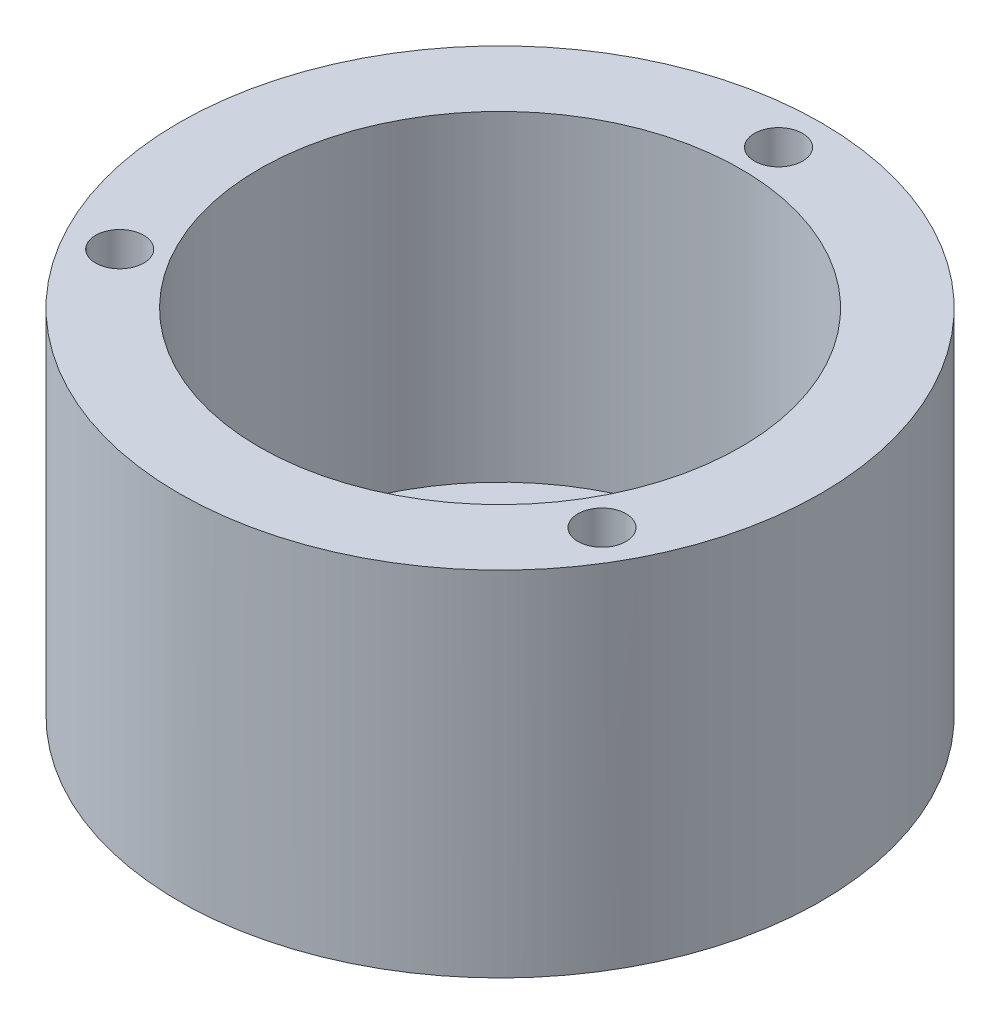
from build123d import *

# Parameters (mm, degrees)
SKETCH1_R           = 20
SKETCH1_R_2         = 15
BOSS_EXTRUDE1_DEPTH = 20
SKETCH2_R           = 20
SKETCH2_R_2         = 3
SKETCH2_R_3         = 2
BOSS_EXTRUDE2_DEPTH = 2
SKETCH3_R           = 1.5
CUT_EXTRUDE1_DEPTH  = 4


with BuildPart() as part:
    # Sketch1 → Boss-Extrude1 (new body)
    with BuildSketch(Plane(origin=(0, 0, 0), x_dir=(1, 0, 0), z_dir=(0, 1, 0))):
        Circle(SKETCH1_R)
        Circle(SKETCH1_R_2, mode=Mode.SUBTRACT)
    extrude(amount=BOSS_EXTRUDE1_DEPTH)

    # Sketch2 → Boss-Extrude2 (add)
    with BuildSketch(Plane.XZ):
        Circle(SKETCH2_R)
        Circle(SKETCH2_R_2, mode=Mode.SUBTRACT)
        with Locations((6, 7.463372557)):
            Circle(SKETCH2_R_3, mode=Mode.SUBTRACT)
        with Locations((7.463372557, -6)):
            Circle(SKETCH2_R_3, mode=Mode.SUBTRACT)
        with Locations((-6, -7.463372557)):
            Circle(SKETCH2_R_3, mode=Mode.SUBTRACT)
        with Locations((-7.463372557, 6)):
            Circle(SKETCH2_R_3, mode=Mode.SUBTRACT)
    extrude(amount=BOSS_EXTRUDE2_DEPTH)

    # Sketch3 → Cut-Extrude1 (cut)
    with BuildSketch(Plane(origin=(0, 20, 0), x_dir=(1, 0, 0), z_dir=(0, 1, 0))):
        with Locations((0, 17.343709181)):
            Circle(SKETCH3_R)
        with Locations((15.020092746, -8.67185459)):
            Circle(SKETCH3_R)
        with Locations((-15.020092746, -8.67185459)):
            Circle(SKETCH3_R)
    extrude(amount=-CUT_EXTRUDE1_DEPTH, mode=Mode.SUBTRACT)


solid = part.part
